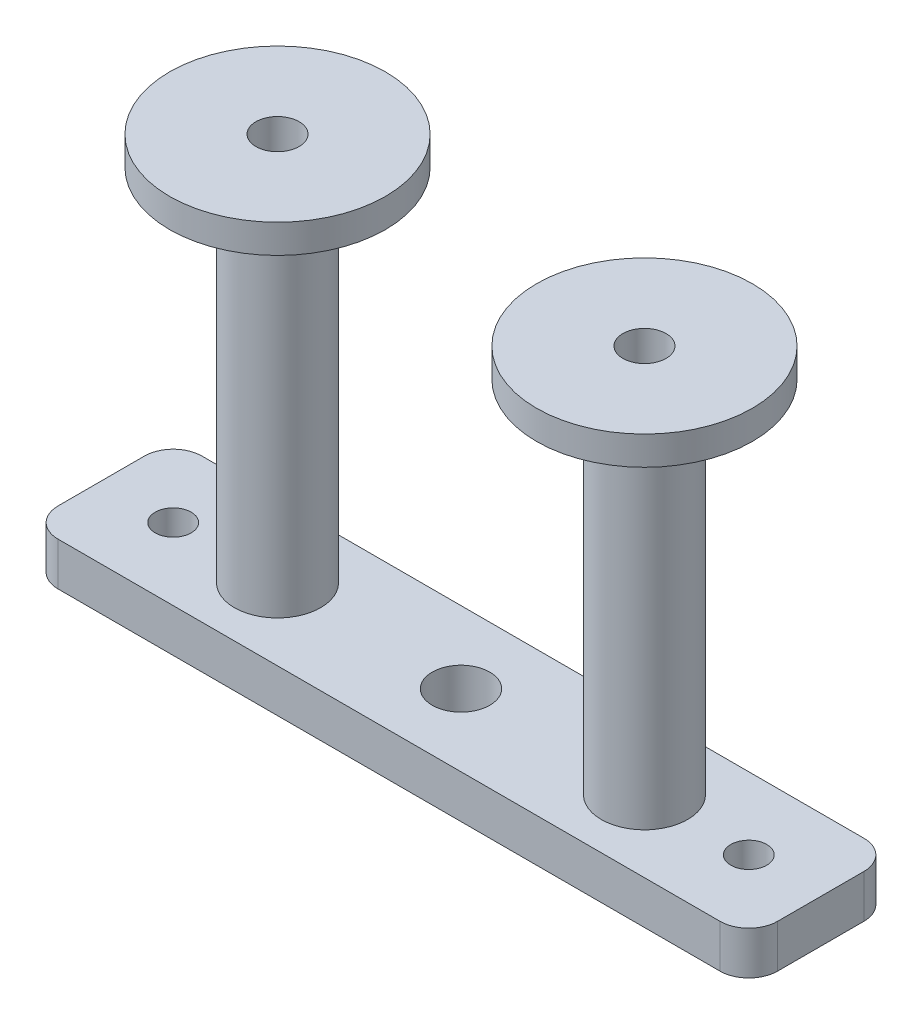
from build123d import *

# Parameters (mm, degrees)
BOSS_EXTRUDE8_DEPTH  = 3
CUT_EXTRUDE8_DEPTH   = 3
BOSS_EXTRUDE9_DEPTH  = 25
SKETCH17_R           = 7.5
BOSS_EXTRUDE10_DEPTH = 2
SKETCH18_R           = 1.5
CUT_EXTRUDE9_DEPTH   = 62
SKETCH19_R           = 7.5
BOSS_EXTRUDE11_DEPTH = 2
SKETCH21_R           = 1.5
CUT_EXTRUDE10_DEPTH  = 52
CUT_EXTRUDE11_DEPTH  = 22


with BuildPart() as part:
    # Sketch1 → Boss-Extrude8 (new body)
    with BuildSketch(Plane(origin=(0, 0, 0), x_dir=(1, 0, 0), z_dir=(0, 1, 0))):
        with BuildLine():
            Line((2, 0), (48, 0))
            ThreePointArc((48, 0), (49.414213562, 0.585786438), (50, 2))
            Line((50, 2), (50, 8))
            ThreePointArc((50, 8), (49.414213562, 9.414213562), (48, 10))
            Line((48, 10), (2, 10))
            ThreePointArc((2, 10), (0.585786438, 9.414213562), (0, 8))
            Line((0, 8), (0, 2))
            ThreePointArc((0, 2), (0.585786438, 0.585786438), (2, 0))
        make_face()
    extrude(amount=BOSS_EXTRUDE8_DEPTH)

    # Sketch15 → Cut-Extrude8 (cut)
    with BuildSketch(Plane(origin=(0, 3, 0), x_dir=(1, 0, 0), z_dir=(0, 1, 0))):
        with BuildLine():
            Line((3.75, 5), (5, 5))
            Line((5, 5), (6.25, 5))
            ThreePointArc((6.25, 5), (5, 6.25), (3.75, 5))
        make_face()
        with BuildLine():
            Line((6.25, 5), (5, 5))
            Line((5, 5), (3.75, 5))
            ThreePointArc((3.75, 5), (5, 3.75), (6.25, 5))
        make_face()
        with BuildLine():
            ThreePointArc((46.25, 5), (45, 6.25), (43.75, 5))
            Line((43.75, 5), (45, 5))
            Line((45, 5), (46.25, 5))
        make_face()
        with BuildLine():
            Line((45, 5), (43.75, 5))
            ThreePointArc((43.75, 5), (45, 3.75), (46.25, 5))
            Line((46.25, 5), (45, 5))
        make_face()
    extrude(amount=-CUT_EXTRUDE8_DEPTH, mode=Mode.SUBTRACT)

    # Sketch16 → Boss-Extrude9 (add)
    with BuildSketch(Plane(origin=(0, 3, 0), x_dir=(1, 0, 0), z_dir=(0, 1, 0))):
        with BuildLine():
            Line((9.25, 5), (12.25, 5))
            Line((12.25, 5), (15.25, 5))
            ThreePointArc((15.25, 5), (12.25, 8), (9.25, 5))
        make_face()
        with BuildLine():
            Line((15.25, 5), (12.25, 5))
            Line((12.25, 5), (9.25, 5))
            ThreePointArc((9.25, 5), (12.25, 2), (15.25, 5))
        make_face()
        with BuildLine():
            ThreePointArc((40.75, 5), (37.75, 8), (34.75, 5))
            Line((34.75, 5), (37.75, 5))
            Line((37.75, 5), (40.75, 5))
        make_face()
        with BuildLine():
            Line((37.75, 5), (34.75, 5))
            ThreePointArc((34.75, 5), (37.75, 2), (40.75, 5))
            Line((40.75, 5), (37.75, 5))
        make_face()
    extrude(amount=BOSS_EXTRUDE9_DEPTH)

    # Sketch17 → Boss-Extrude10 (add)
    with BuildSketch(Plane(origin=(0, 28, 0), x_dir=(1, 0, 0), z_dir=(0, 1, 0))):
        with Locations((12.25, 5)):
            Circle(SKETCH17_R)
    extrude(amount=BOSS_EXTRUDE10_DEPTH)

    # Sketch18 → Cut-Extrude9 (cut)
    with BuildSketch(Plane(origin=(0, 30, 0), x_dir=(1, 0, 0), z_dir=(0, 1, 0))):
        with Locations((12.25, 5)):
            Circle(SKETCH18_R)
    extrude(amount=-CUT_EXTRUDE9_DEPTH, mode=Mode.SUBTRACT)

    # Sketch19 → Boss-Extrude11 (add)
    with BuildSketch(Plane(origin=(0, 28, 0), x_dir=(1, 0, 0), z_dir=(0, 1, 0))):
        with Locations((37.75, 5)):
            Circle(SKETCH19_R)
    extrude(amount=BOSS_EXTRUDE11_DEPTH)

    # Sketch21 → Cut-Extrude10 (cut)
    with BuildSketch(Plane(origin=(0, 30, 0), x_dir=(1, 0, 0), z_dir=(0, 1, 0))):
        with Locations((37.75, 5)):
            Circle(SKETCH21_R)
    extrude(amount=-CUT_EXTRUDE10_DEPTH, mode=Mode.SUBTRACT)

    # Sketch23 → Cut-Extrude11 (cut)
    with BuildSketch(Plane.XZ):
        with BuildLine():
            ThreePointArc((27, -5), (25, -3), (23, -5))
            Line((23, -5), (27, -5))
        make_face()
        with BuildLine():
            Line((27, -5), (23, -5))
            ThreePointArc((23, -5), (25, -7), (27, -5))
        make_face()
    extrude(amount=-CUT_EXTRUDE11_DEPTH, mode=Mode.SUBTRACT)


solid = part.part
